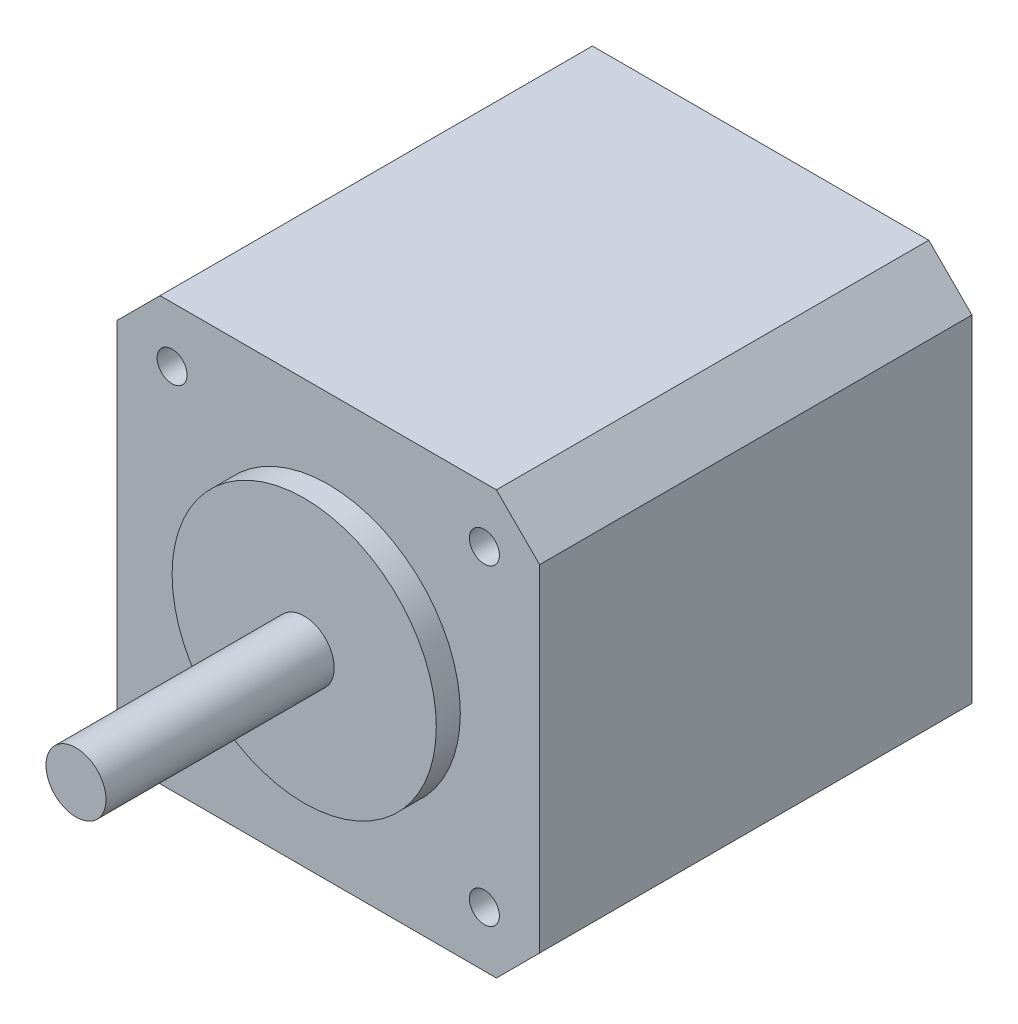
from build123d import *

# Parameters (mm, degrees)
BOSS_EXTRUDE1_DEPTH       = 36
SKETCH2_R                 = 11
BOSS_EXTRUDE2_DEPTH       = 2
SKETCH3_R                 = 2.5
BOSS_EXTRUDE3_DEPTH       = 21
M3X0_5_TAPPED_HOLE1_D     = 2.5
M3X0_5_TAPPED_HOLE1_DEPTH = 5
M3X0_5_TAPPED_HOLE1_TIP   = 0.751075774


with BuildPart() as part:
    # Sketch1 → Boss-Extrude1 (new body)
    with BuildSketch(Plane.XY):
        Polygon((-14.003805752, -17.6), (14.003805752, -17.6), (17.6, -14.003805752), (17.6, 14.003805752), (14.003805752, 17.6), (-14.003805752, 17.6), (-17.6, 14.003805752), (-17.6, -14.003805752), align=None)
    extrude(amount=-BOSS_EXTRUDE1_DEPTH)

    # Sketch2 → Boss-Extrude2 (add)
    with BuildSketch(Plane.XY):
        Circle(SKETCH2_R)
    extrude(amount=BOSS_EXTRUDE2_DEPTH)

    # Sketch3 → Boss-Extrude3 (add)
    with BuildSketch(Plane.XY):
        Circle(SKETCH3_R)
    extrude(amount=BOSS_EXTRUDE3_DEPTH)

    # M3x0.5 Tapped Hole1
    with Locations(Plane.XY):
        with Locations((-13, -13), (13, -13), (13, 13), (-13, 13)):
            Hole(M3X0_5_TAPPED_HOLE1_D / 2, depth=M3X0_5_TAPPED_HOLE1_DEPTH)
            with Locations((0, 0, -(M3X0_5_TAPPED_HOLE1_DEPTH + M3X0_5_TAPPED_HOLE1_TIP / 2))):  # 118° drill point
                Cone(0, M3X0_5_TAPPED_HOLE1_D / 2, M3X0_5_TAPPED_HOLE1_TIP, mode=Mode.SUBTRACT)


solid = part.part
